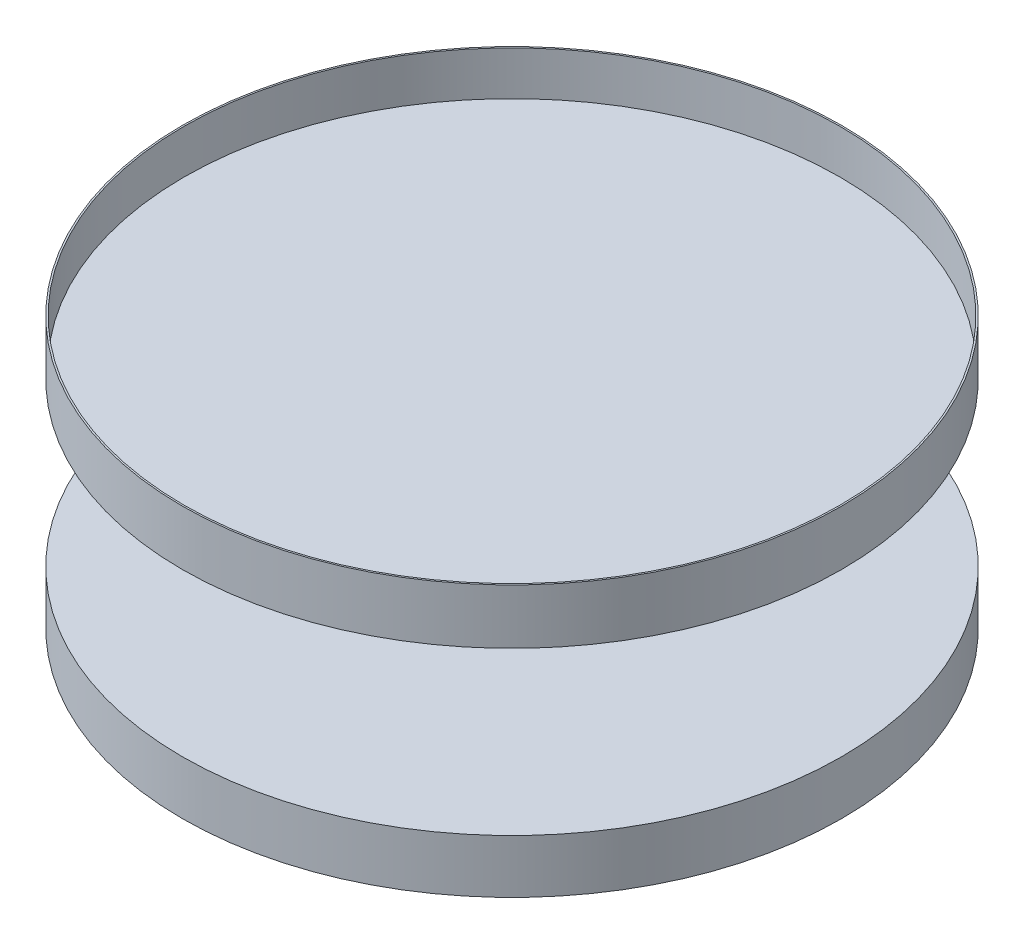
from build123d import *


with BuildPart() as part:
    # Sketch2 → Revolve2 (revolve)
    with BuildSketch(Plane.XY):
        Polygon((0, -99.619792047), (645.624954417, -99.619792047), (645.624954417, 5.380207953), (16.14062386, 5.380207953), (16.14062386, 322.812477209), (645.624954417, 322.812477209), (645.624954417, 430.416636278), (642.396829645, 430.416636278), (642.396829645, 344.333309023), (0, 344.333309023), align=None)
    revolve(axis=Axis((0, -99.619792047, 0), (0, 1, 0)))


solid = part.part
